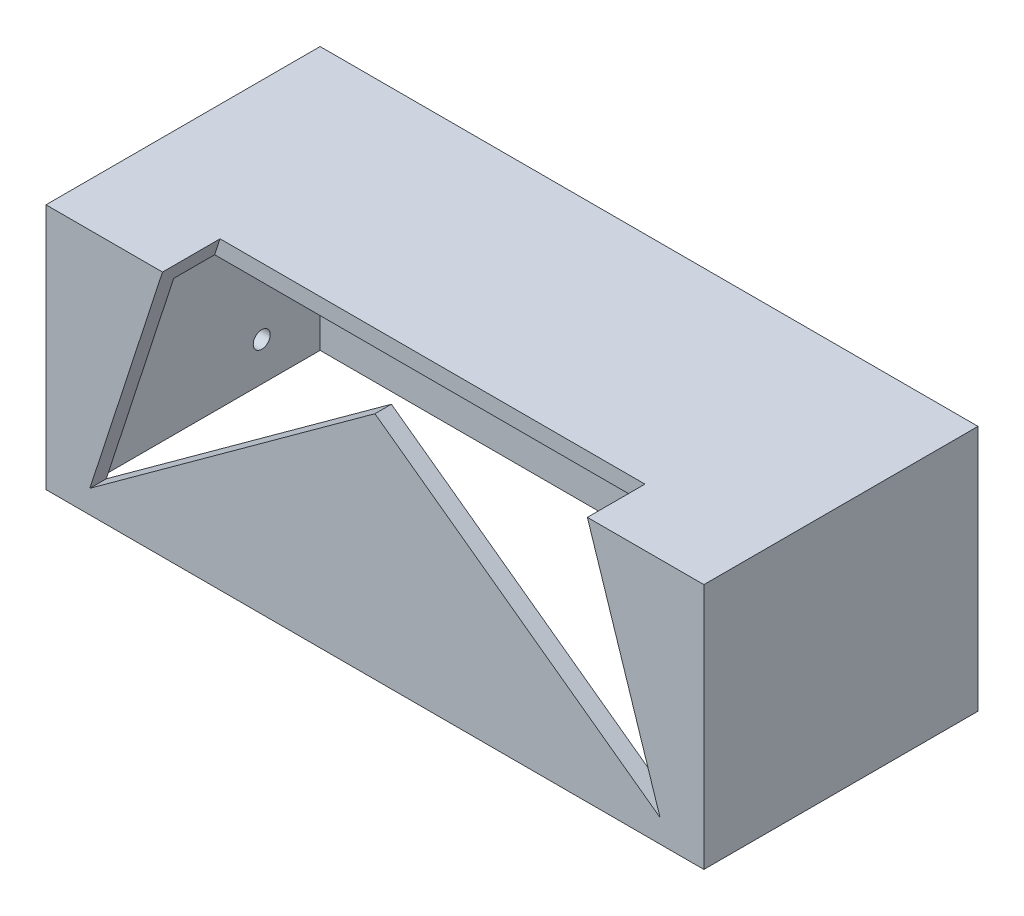
from build123d import *

# Parameters (mm, degrees)
CROQUIS2_W                   = 120
CROQUIS2_H                   = 45
SALIENTE_EXTRUIR1_DEPTH      = 5
SALIENTE_EXTRUIR1_DEPTH_BACK = 45
VACIADO1_T                   = -3
CORTAR_EXTRUIR2_START        = -10.5
CORTAR_EXTRUIR2_DEPTH        = 10.5
CORTAR_EXTRUIR3_REACH        = 122
CROQUIS4_R                   = 1.55
CROQUIS4_W                   = 8
CROQUIS4_H                   = 10.5
CORTAR_EXTRUIR4_REACH        = 52
CROQUIS5_R                   = 1.55


with BuildPart() as part:
    # Croquis2 → Saliente-Extruir1 (new body, two sides)
    with BuildSketch(Plane.XY.offset(-12)) as saliente_extruir1_sk:
        with Locations((0, -53.288987008)):
            Rectangle(CROQUIS2_W, CROQUIS2_H)
    extrude(amount=SALIENTE_EXTRUIR1_DEPTH)
    extrude(saliente_extruir1_sk.sketch, amount=-SALIENTE_EXTRUIR1_DEPTH_BACK)

    # Vaciado1
    vaciado1_openings = [part.faces().sort_by_distance(p)[0] for p in [
        (0, -75.788987008, -32),
    ]]
    offset(amount=VACIADO1_T, openings=vaciado1_openings, kind=Kind.INTERSECTION)

    # Croquis3 → Cortar-Extruir2 (cut)
    with BuildSketch(Plane.XY.offset(-7).offset(CORTAR_EXTRUIR2_START)):
        Polygon((0, 88.470820393), (-19.862936734, 27.338987008), (-84.140750237, 27.338987008), (-32.138906752, -10.442563819), (-52.001843485, -71.574397204), (0, -33.792846378), (52.001843485, -71.574397204), (32.138906752, -10.442563819), (84.140750237, 27.338987008), (19.862936734, 27.338987008), align=None)
    extrude(amount=CORTAR_EXTRUIR2_DEPTH, mode=Mode.SUBTRACT)

    # Croquis4 → Cortar-Extruir3 (cut, up to next)
    with BuildSketch(Plane.ZY.offset(60), mode=Mode.PRIVATE) as cortar_extruir3_sk1:
        with Locations((-43.35, -37.771593165)):
            Circle(CROQUIS4_R)
    cortar_extruir3_tool1 = extrude(cortar_extruir3_sk1.sketch, amount=-CORTAR_EXTRUIR3_REACH, mode=Mode.PRIVATE) & part.part
    add(cortar_extruir3_tool1.solids().sort_by_distance((-60, -37.771593, -43.35))[0], mode=Mode.SUBTRACT)
    # Croquis4 → Cortar-Extruir3 (cut, up to next)
    with BuildSketch(Plane.ZY.offset(60), mode=Mode.PRIVATE) as cortar_extruir3_sk2:
        with Locations((-43.35, -68.73680548)):
            Circle(CROQUIS4_R)
    cortar_extruir3_tool2 = extrude(cortar_extruir3_sk2.sketch, amount=-CORTAR_EXTRUIR3_REACH, mode=Mode.PRIVATE) & part.part
    add(cortar_extruir3_tool2.solids().sort_by_distance((-60, -68.736805, -43.35))[0], mode=Mode.SUBTRACT)
    # Croquis4 → Cortar-Extruir3 (cut, up to next)
    with BuildSketch(Plane.ZY.offset(60), mode=Mode.PRIVATE) as cortar_extruir3_sk3:
        with Locations((-48.5, -53.254199323)):
            Rectangle(CROQUIS4_W, CROQUIS4_H)
    cortar_extruir3_tool3 = extrude(cortar_extruir3_sk3.sketch, amount=-CORTAR_EXTRUIR3_REACH, mode=Mode.PRIVATE) & part.part
    add(cortar_extruir3_tool3.solids().sort_by_distance((-60, -53.254199, -48.5))[0], mode=Mode.SUBTRACT)

    # Croquis5 → Cortar-Extruir4 (cut, up to next)
    with BuildSketch(Plane(origin=(0, 0, -57), x_dir=(-1, 0, 0), z_dir=(0, 0, -1)), mode=Mode.PRIVATE) as cortar_extruir4_sk1:
        with Locations((7.617393842, -53.254199323)):
            Circle(CROQUIS5_R)
    cortar_extruir4_tool1 = extrude(cortar_extruir4_sk1.sketch, amount=-CORTAR_EXTRUIR4_REACH, mode=Mode.PRIVATE) & part.part
    add(cortar_extruir4_tool1.solids().sort_by_distance((-7.617394, -53.254199, -57))[0], mode=Mode.SUBTRACT)


solid = part.part
